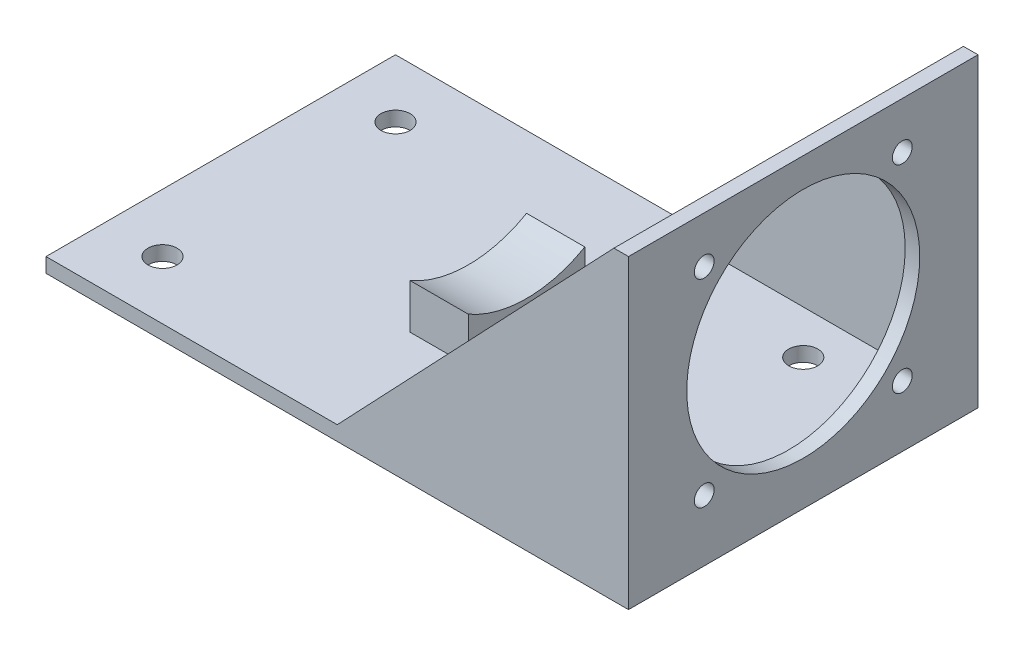
from build123d import *

# Parameters (mm, degrees)
SKETCH1_W           = 254
SKETCH1_H           = 152.4
BOSS_EXTRUDE1_DEPTH = 6.35
SKETCH2_W           = 152.4
SKETCH2_H           = 127
SKETCH2_R           = 50.8
SKETCH2_R_2         = 4.318
BOSS_EXTRUDE2_DEPTH = 6.35
BOSS_EXTRUDE3_DEPTH = 6.35
BOSS_EXTRUDE4_DEPTH = 6.35
SKETCH5_W           = 25.4
SKETCH5_H           = 50.8
BOSS_EXTRUDE5_DEPTH = 25.4
SKETCH6_R           = 50.8
CUT_EXTRUDE1_DEPTH  = 25.4
SKETCH7_R           = 6.35
CUT_EXTRUDE2_DEPTH  = 25.4


with BuildPart() as part:
    # Sketch1 → Boss-Extrude1 (new body)
    with BuildSketch(Plane(origin=(0, 0, 0), x_dir=(1, 0, 0), z_dir=(0, 1, 0))):
        Rectangle(SKETCH1_W, SKETCH1_H)
    extrude(amount=BOSS_EXTRUDE1_DEPTH)

    # Sketch2 → Boss-Extrude2 (add)
    with BuildSketch(Plane(origin=(127, 0, 0), x_dir=(0, 0, -1), z_dir=(1, 0, 0))):
        with Locations((0, 69.85)):
            Rectangle(SKETCH2_W, SKETCH2_H)
        with Locations((0, 69.85)):
            Circle(SKETCH2_R, mode=Mode.SUBTRACT)
        with Locations((-43.18, 26.67)):
            Circle(SKETCH2_R_2, mode=Mode.SUBTRACT)
        with Locations((43.18, 26.67)):
            Circle(SKETCH2_R_2, mode=Mode.SUBTRACT)
        with Locations((43.18, 113.03)):
            Circle(SKETCH2_R_2, mode=Mode.SUBTRACT)
        with Locations((-43.18, 113.03)):
            Circle(SKETCH2_R_2, mode=Mode.SUBTRACT)
    extrude(amount=-BOSS_EXTRUDE2_DEPTH)

    # Sketch3 → Boss-Extrude3 (add)
    with BuildSketch(Plane.XY.offset(76.2)):
        Polygon((120.65, 133.35), (0, 6.35), (120.65, 6.35), align=None)
    extrude(amount=-BOSS_EXTRUDE3_DEPTH)

    # Sketch4 → Boss-Extrude4 (add)
    with BuildSketch(Plane(origin=(0, 0, -76.2), x_dir=(-1, 0, 0), z_dir=(0, 0, -1))):
        Polygon((-120.65, 133.35), (0, 6.35), (-120.65, 6.35), align=None)
    extrude(amount=-BOSS_EXTRUDE4_DEPTH)

    # Sketch5 → Boss-Extrude5 (add)
    with BuildSketch(Plane(origin=(0, 6.35, 0), x_dir=(1, 0, 0), z_dir=(0, 1, 0))):
        with Locations((-6.35, 0)):
            Rectangle(SKETCH5_W, SKETCH5_H)
    extrude(amount=BOSS_EXTRUDE5_DEPTH)

    # Sketch6 → Cut-Extrude1 (cut)
    with BuildSketch(Plane.ZY.offset(19.05)):
        with Locations((0, 69.85)):
            Circle(SKETCH6_R)
    extrude(amount=-CUT_EXTRUDE1_DEPTH, mode=Mode.SUBTRACT)

    # Sketch7 → Cut-Extrude2 (cut)
    with BuildSketch(Plane(origin=(0, 6.35, 0), x_dir=(1, 0, 0), z_dir=(0, 1, 0))):
        with Locations((-101.6, 50.8)):
            Circle(SKETCH7_R)
        with Locations((-101.6, -50.8)):
            Circle(SKETCH7_R)
        with Locations((76.2, -50.8)):
            Circle(SKETCH7_R)
        with Locations((76.2, 50.8)):
            Circle(SKETCH7_R)
    extrude(amount=-CUT_EXTRUDE2_DEPTH, mode=Mode.SUBTRACT)


solid = part.part
